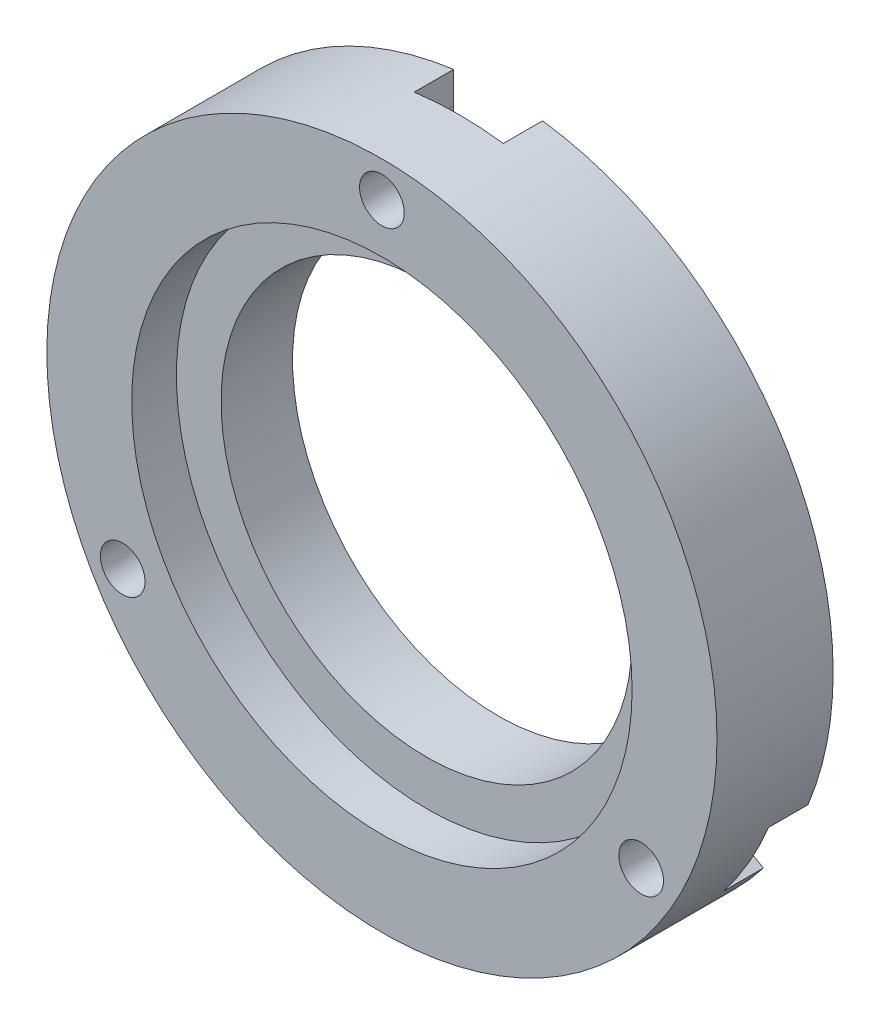
from build123d import *

# Parameters (mm, degrees)
SKETCH_1_R          = 18.75
SKETCH_1_R_2        = 11.5
SKETCH_1_R_3        = 1.25
EXTRUDE_1_DEPTH     = 6.5
SKETCH_2_R          = 14
CUT_EXTRUDE_1_DEPTH = 2.5
CUT_EXTRUDE_2_DEPTH = 2.2
CUT_EXTRUDE_3_DEPTH = 2.2


with BuildPart() as part:
    # 草图1 → 凸台-拉伸1 (new body)
    with BuildSketch(Plane.XY):
        Circle(SKETCH_1_R)
        Circle(SKETCH_1_R_2, mode=Mode.SUBTRACT)
        with Locations((0, 16.75)):
            Circle(SKETCH_1_R_3, mode=Mode.SUBTRACT)
        with Locations((-14.505925513, -8.375)):
            Circle(SKETCH_1_R_3, mode=Mode.SUBTRACT)
        with Locations((14.505925513, -8.375)):
            Circle(SKETCH_1_R_3, mode=Mode.SUBTRACT)
    extrude(amount=EXTRUDE_1_DEPTH)

    # 草图2 → 切除-拉伸1 (cut)
    with BuildSketch(Plane.XY.offset(6.5)):
        Circle(SKETCH_2_R)
    extrude(amount=-CUT_EXTRUDE_1_DEPTH, mode=Mode.SUBTRACT)

    # 草图3 → 切除-拉伸2 (cut)
    with BuildSketch(Plane(origin=(0, 0, 0), x_dir=(-1, 0, 0), z_dir=(0, 0, -1))):
        with BuildLine():
            ThreePointArc((16.972613326, -7.968243025), (12.340862004, -7.125), (15.387007546, -10.714592796))
            ThreePointArc((15.387007546, -10.714592796), (16.237976321, -9.375), (16.972613326, -7.968243025))
        make_face()
        with BuildLine():
            ThreePointArc((-15.387007546, -10.714592796), (-12.340862004, -7.125), (-16.972613326, -7.968243025))
            ThreePointArc((-16.972613326, -7.968243025), (-16.237976321, -9.375), (-15.387007546, -10.714592796))
        make_face()
        with BuildLine():
            ThreePointArc((-1.58560578, 18.682835821), (0, 14.25), (1.58560578, 18.682835821))
            ThreePointArc((1.58560578, 18.682835821), (0, 18.75), (-1.58560578, 18.682835821))
        make_face()
    extrude(amount=-CUT_EXTRUDE_2_DEPTH, mode=Mode.SUBTRACT)

    # 草图4 → 切除-拉伸3 (cut)
    with BuildSketch(Plane(origin=(0, 0, 0), x_dir=(-1, 0, 0), z_dir=(0, 0, -1))):
        with BuildLine():
            Line((-14.815508707, -11.430866213), (-13.331315009, -10.581873391))
            ThreePointArc((-13.331315009, -10.581873391), (-14.344856115, -10.869805934), (-15.387007546, -10.714592796))
            ThreePointArc((-15.387007546, -10.714592796), (-15.122080143, -11.08535936), (-14.848220713, -11.449578231))
            Line((-14.848220713, -11.449578231), (-14.815508707, -11.430866213))
        make_face()
        with BuildLine():
            Line((-15.812800928, -6.24378517), (-17.28904082, -7.10668269))
            Line((-17.28904082, -7.10668269), (-17.339016827, -7.135894861))
            ThreePointArc((-17.339016827, -7.135894861), (-17.16086221, -7.554290715), (-16.972613326, -7.968243025))
            ThreePointArc((-16.972613326, -7.968243025), (-16.580385342, -6.979788038), (-15.812800928, -6.24378517))
        make_face()
        with BuildLine():
            Line((13.313677037, -10.572394724), (14.799088157, -11.419407212))
            Line((14.799088157, -11.419407212), (14.849374642, -11.448081618))
            ThreePointArc((14.849374642, -11.448081618), (15.122638772, -11.084597268), (15.387007546, -10.714592796))
            ThreePointArc((15.387007546, -10.714592796), (14.334866424, -10.869140892), (13.313677037, -10.572394724))
        make_face()
        with BuildLine():
            Line((17.339735967, -7.134147223), (17.307174882, -7.115173804))
            Line((17.307174882, -7.115173804), (15.829828681, -6.254320768))
            ThreePointArc((15.829828681, -6.254320768), (16.585956131, -6.988106842), (16.972613326, -7.968243025))
            ThreePointArc((16.972613326, -7.968243025), (17.161242887, -7.553425882), (17.339735967, -7.134147223))
        make_face()
        with BuildLine():
            Line((-2.491515254, 18.583725454), (-2.491666175, 18.546040017))
            Line((-2.491666175, 18.546040017), (-2.498513672, 16.836194159))
            ThreePointArc((-2.498513672, 16.836194159), (-2.241100016, 17.857912776), (-1.58560578, 18.682835821))
            ThreePointArc((-1.58560578, 18.682835821), (-2.039162744, 18.638785242), (-2.491515254, 18.583725454))
        make_face()
        with BuildLine():
            ThreePointArc((1.58560578, 18.682835821), (2.245518917, 17.848928929), (2.499123891, 16.816179894))
            Line((2.499123891, 16.816179894), (2.489952664, 18.526089903))
            Line((2.489952664, 18.526089903), (2.489642185, 18.58397648))
            ThreePointArc((2.489642185, 18.58397648), (2.038223439, 18.638887982), (1.58560578, 18.682835821))
        make_face()
    extrude(amount=-CUT_EXTRUDE_3_DEPTH, mode=Mode.SUBTRACT)


solid = part.part
